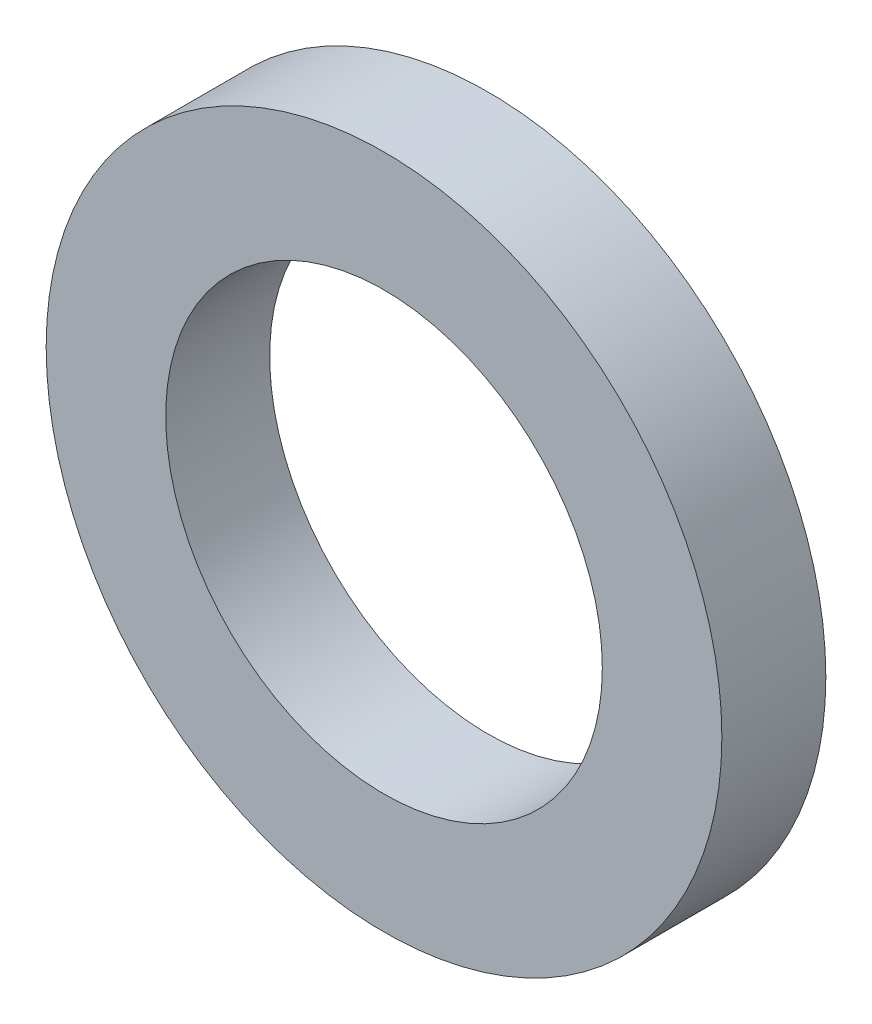
from build123d import *

# Parameters (mm, degrees)
SKETCH1_R           = 6.5
SKETCH1_R_2         = 4.2
BOSS_EXTRUDE1_DEPTH = 2


with BuildPart() as part:
    # Sketch1 → Boss-Extrude1 (new body)
    with BuildSketch(Plane.XY):
        Circle(SKETCH1_R)
        Circle(SKETCH1_R_2, mode=Mode.SUBTRACT)
    extrude(amount=BOSS_EXTRUDE1_DEPTH)


solid = part.part
